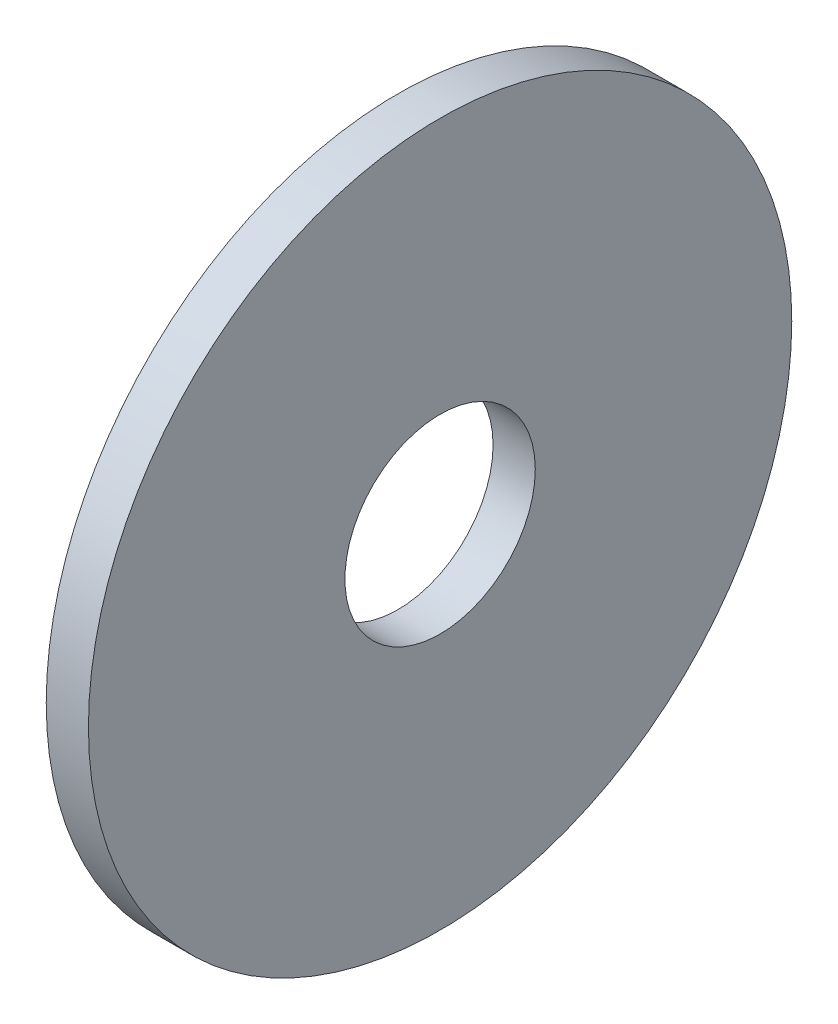
from build123d import *

# Parameters (mm, degrees)
SKETCH1_R           = 9.525
SKETCH1_R_2         = 2.5781
BOSS_EXTRUDE1_DEPTH = 1.143


with BuildPart() as part:
    # Sketch1 → Boss-Extrude1 (new body)
    with BuildSketch(Plane(origin=(0, 0, 0), x_dir=(0, 0, -1), z_dir=(1, 0, 0))):
        Circle(SKETCH1_R)
        Circle(SKETCH1_R_2, mode=Mode.SUBTRACT)
    extrude(amount=BOSS_EXTRUDE1_DEPTH)


solid = part.part
